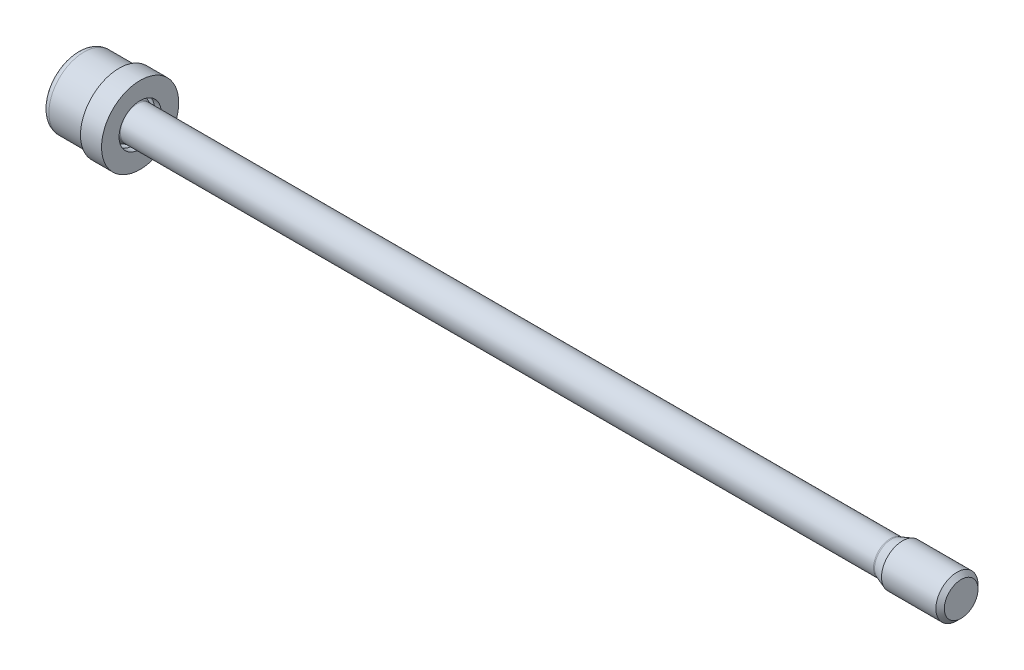
from build123d import *

# Parameters (mm, degrees)
AUFSATZ_LINEAR_AUSTRAGEN1_REACH = 128
SKIZZE2_R                       = 3
VERRUNDUNG1_R                   = 1
VERRUNDUNG2_R                   = 0.5


with BuildPart() as part:
    # Skizze1 → Rotation1 (revolve)
    with BuildSketch(Plane.XY):
        Polygon((0, 5), (6, 5), (6, 3.309925586), (8.5, 2.4), (116, 2.4), (117.648486452, 3), (125.4, 3), (126, 2.4), (126, 0), (4.732050808, 0), (3, 3), (0, 3), align=None)
    revolve(axis=Axis((0, 0, 0), (-1, 0, 0)))

    # Skizze2 → Aufsatz-Linear austragen1 (add, up to next)
    with BuildSketch(Plane.ZY, mode=Mode.PRIVATE) as aufsatz_linear_austragen1_sk1:
        Circle(SKIZZE2_R)
        Polygon((-2.886751346, 0), (-1.443375673, -2.5), (1.443375673, -2.5), (2.886751346, 0), (1.443375673, 2.5), (-1.443375673, 2.5), align=None, mode=Mode.SUBTRACT)
    aufsatz_linear_austragen1_tool1 = extrude(aufsatz_linear_austragen1_sk1.sketch, amount=-AUFSATZ_LINEAR_AUSTRAGEN1_REACH, mode=Mode.PRIVATE) - part.part
    add(aufsatz_linear_austragen1_tool1.solids().sort_by_distance((0, 0, -2.915147))[0])

    # Verrundung1
    verrundung1_edges = [part.edges().sort_by_distance(p)[0] for p in [
        (0, -5, 0),
    ]]
    fillet(verrundung1_edges, radius=VERRUNDUNG1_R)

    # Verrundung2
    verrundung2_edges = [part.edges().sort_by_distance(p)[0] for p in [
        (116, -2.4, 0),
        (8.5, -2.4, 0),
        (6, -3.309925586, 0),
    ]]
    fillet(verrundung2_edges, radius=VERRUNDUNG2_R)


with BuildPart() as body_2:
    # Skizze3 → Rotation2 (revolve)
    with BuildSketch(Plane.XY):
        Polygon((6, 5.5), (9, 5.5), (9, 3), (8.060608065, 3), (6, 3.75), align=None)
    revolve(axis=Axis((0, 0, 0), (1, 0, 0)))


solid = Compound([part.part, body_2.part])
